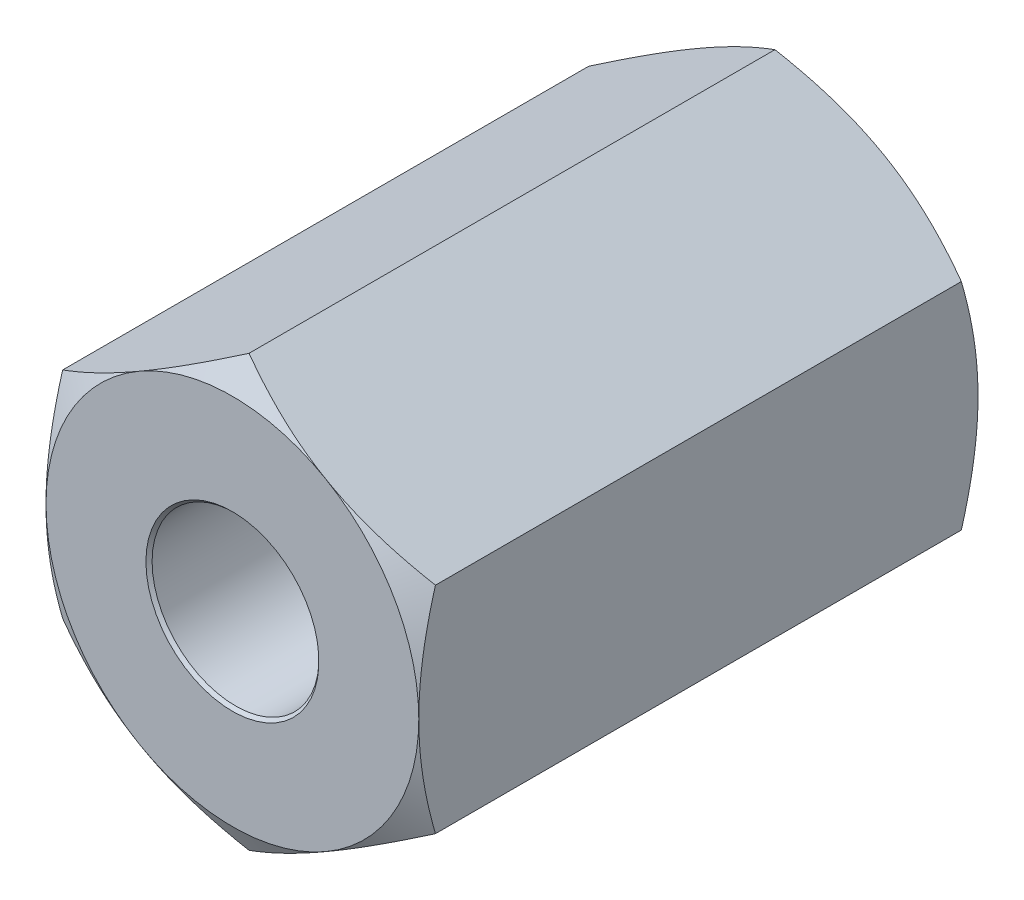
from build123d import *

# Parameters (mm, degrees)
EXTRUDE1_DEPTH          = 4.7625
EXTRUDE1_DEPTH_BACK     = 4.7625
SKETCH1_R               = 1.4224
SKETCH8_OUTSIDE_W       = 51.56
SKETCH8_OUTSIDE_H       = 52.542
SKETCH8_OUTSIDE_R       = 3.175
EXTRUDE4_DEPTH          = 11.688642726
EXTRUDE4_DRAFT          = -60
MIRROR1_COPY_1_SKETCH_W = 51.56
MIRROR1_COPY_1_SKETCH_H = 52.542
MIRROR1_COPY_1_SKETCH_R = 3.175
MIRROR1_COPY_1_DEPTH    = 11.688642726
MIRROR1_COPY_1_DRAFT    = -60


with BuildPart() as part:
    # Sketch1 → Extrude1 (new, two sides: drawn at the far end of the back side and taken through both)
    with BuildSketch(Plane.XY.offset(-EXTRUDE1_DEPTH_BACK)):
        Polygon((0, 3.666174209), (-3.175, 1.833087105), (-3.175, -1.833087105), (0, -3.666174209), (3.175, -1.833087105), (3.175, 1.833087105), align=None)
        with Locations(Location((0, 0, 0), (0, 0, 180))):
            Circle(SKETCH1_R, mode=Mode.SUBTRACT)
    extrude(amount=EXTRUDE1_DEPTH + EXTRUDE1_DEPTH_BACK)

    # Extrude3 cone 1 section (through the dimple's axis) → Extrude3 (revolve, cut)
    with BuildSketch(Plane(origin=(0, 0, -4.7625), x_dir=(0, 1, 0), z_dir=(1, 0, 0))):
        Polygon((0, 0), (1.4732, 0), (0, 1.579813584), align=None)
    extrude3 = revolve(axis=Axis((0, 0, -4.7625), (0, 0, 1)), mode=Mode.SUBTRACT)


with BuildPart() as extrude4_tool:
    # Sketch8 outside → Extrude4 (with draft: the straight prism first)
    with BuildSketch(Plane(origin=(0, 0, -4.7625), x_dir=(-1, 0, 0), z_dir=(0, 0, -1))):
        Rectangle(SKETCH8_OUTSIDE_W, SKETCH8_OUTSIDE_H)
        Circle(SKETCH8_OUTSIDE_R, mode=Mode.SUBTRACT)
    extrude(amount=-EXTRUDE4_DEPTH)
    # Extrude4: the draft: its side faces are tilted about the plane it starts from
    extrude4_sides = [extrude4_tool.faces().sort_by_distance(p)[0] for p in [
        (0, -26.271, 1.081821363),
        (-25.78, 0, 1.081821363),
        (0, 26.271, 1.081821363),
        (25.78, 0, 1.081821363),
        (3.175, 0, 1.081821363),
    ]]
    draft(extrude4_sides, Plane(origin=(0, 0, -4.7625), x_dir=(-1, 0, 0), z_dir=(0, 0, -1)), EXTRUDE4_DRAFT)


with BuildPart() as part_1:
    add(part.part)

    # Extrude4: cut by extrude4_tool
    add(extrude4_tool.part, mode=Mode.SUBTRACT)

    # Mirror1: Extrude3 across plane
    add(extrude3.mirror(Plane.XY), mode=Mode.SUBTRACT)


with BuildPart() as mirror1_copy_1_tool:
    # Mirror1 copy 1 sketch → Mirror1 copy 1 (with draft: the straight prism first)
    with BuildSketch(Plane(origin=(0, 0, 4.7625), x_dir=(-1, 0, 0), z_dir=(0, 0, 1))):
        Rectangle(MIRROR1_COPY_1_SKETCH_W, MIRROR1_COPY_1_SKETCH_H)
        Circle(MIRROR1_COPY_1_SKETCH_R, mode=Mode.SUBTRACT)
    extrude(amount=-MIRROR1_COPY_1_DEPTH)
    # Mirror1 copy 1: the draft: its side faces are tilted about the plane it starts from
    mirror1_copy_1_sides = [mirror1_copy_1_tool.faces().sort_by_distance(p)[0] for p in [
        (0, -26.271, -1.081821363),
        (-25.78, 0, -1.081821363),
        (0, 26.271, -1.081821363),
        (25.78, 0, -1.081821363),
        (3.175, 0, -1.081821363),
    ]]
    draft(mirror1_copy_1_sides, Plane(origin=(0, 0, 4.7625), x_dir=(-1, 0, 0), z_dir=(0, 0, 1)), MIRROR1_COPY_1_DRAFT)


with BuildPart() as part_2:
    add(part_1.part)

    # Mirror1 copy 1: cut by mirror1_copy_1_tool
    add(mirror1_copy_1_tool.part, mode=Mode.SUBTRACT)


solid = part_2.part
